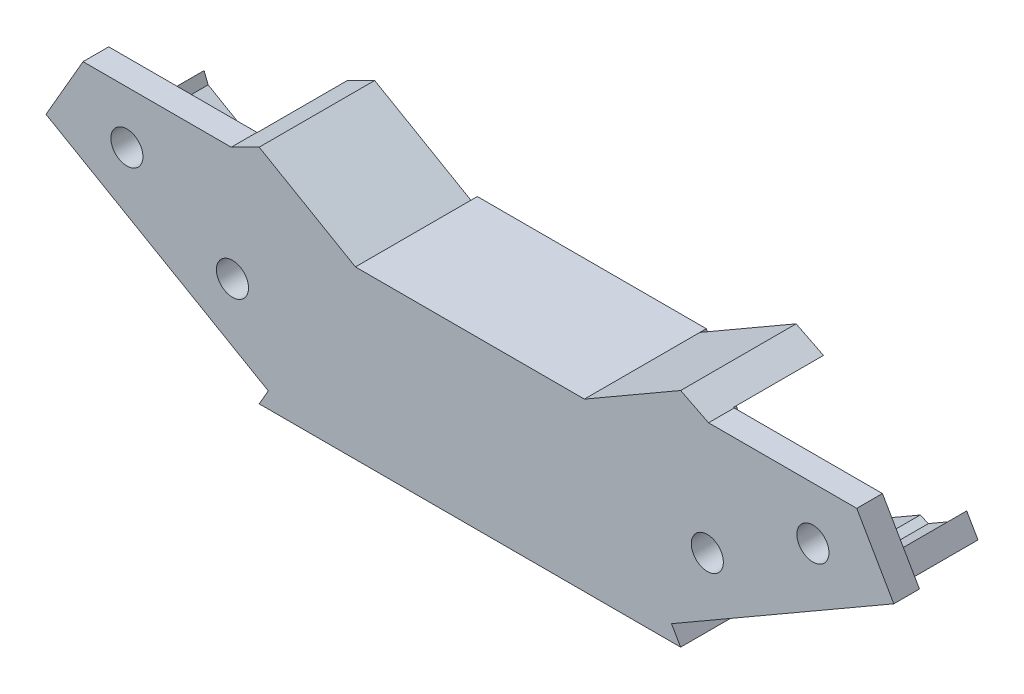
from build123d import *

# Parameters (mm, degrees)
SALIENTE_EXTRUIR1_DEPTH = 7.5
CROQUIS2_R              = 1.25
SALIENTE_EXTRUIR2_DEPTH = 2
SALIENTE_EXTRUIR3_DEPTH = 7


with BuildPart() as part:
    # Croquis1 → Saliente-Extruir1 (new body)
    with BuildSketch(Plane.XY):
        Polygon((-8.919750427, 0), (8.919750427, 0), (16.419750427, -12.990381057), (-16.419750427, -12.990381057), align=None)
    extrude(amount=SALIENTE_EXTRUIR1_DEPTH)

    # Croquis2 → Saliente-Extruir2 (add)
    with BuildSketch(Plane.XY.offset(7.5)):
        Polygon((-8.919750427, 0), (-16.419750427, 4.330127019), (-18.59607878, 3.240107663), (-30.143084163, 3.240107663), (-33.029835509, -1.759892337), (-15.709327434, -11.759892337), (-16.419750427, -12.990381057), (16.419750427, -12.990381057), (15.709327434, -11.759892337), (33.029835509, -1.759892337), (30.143084163, 3.240107663), (18.59607878, 3.240107663), (16.419750427, 4.330127019), (8.919750427, 0), align=None)
        with Locations((-26.726205798, -0.841685406)):
            Circle(CROQUIS2_R, mode=Mode.SUBTRACT)
        with Locations((-18.498964463, -5.591685406)):
            Circle(CROQUIS2_R, mode=Mode.SUBTRACT)
        with Locations((18.498964463, -5.591685406)):
            Circle(CROQUIS2_R, mode=Mode.SUBTRACT)
        with Locations((26.726205798, -0.841685406)):
            Circle(CROQUIS2_R, mode=Mode.SUBTRACT)
    extrude(amount=SALIENTE_EXTRUIR2_DEPTH)

    # Croquis3 → Saliente-Extruir3 (add)
    with BuildSketch(Plane(origin=(0, 0, 7.5), x_dir=(-1, 0, 0), z_dir=(0, 0, -1))):
        Polygon((-18.549679438, 3.263346886), (-16.419750427, 4.330127019), (-8.919750427, 0), (-9.914162027, -1.722371415), align=None)
        Polygon((-30.305258965, -3.332927338), (-24.369581471, -6.759892337), (-23.490602897, -5.237456788), (-26.081610625, -3.741537779), (-26.729742931, -3.993881902), (-29.396625899, -2.454156302), (-29.711298573, -1.645936465), (-30.590277147, -3.168372014), align=None)
        Polygon((-21.307825634, -8.527597894), (-20.660765693, -7.4068572), (-18.160959134, -8.850121189), (-18.808019075, -9.970861884), align=None)
        Polygon((9.914162027, -1.722371415), (18.549679438, 3.263346886), (16.419750427, 4.330127019), (8.919750427, 0), align=None)
        Polygon((18.160959134, -8.850121189), (18.808019075, -9.970861884), (21.307825634, -8.527597894), (20.660765693, -7.4068572), align=None)
        Polygon((29.711298573, -1.645936465), (30.590277147, -3.168372014), (30.305258965, -3.332927338), (24.369581471, -6.759892337), (23.490602897, -5.237456788), (26.081610625, -3.741537779), (26.729742931, -3.993881902), (29.396625899, -2.454156302), align=None)
    extrude(amount=SALIENTE_EXTRUIR3_DEPTH)


solid = part.part
